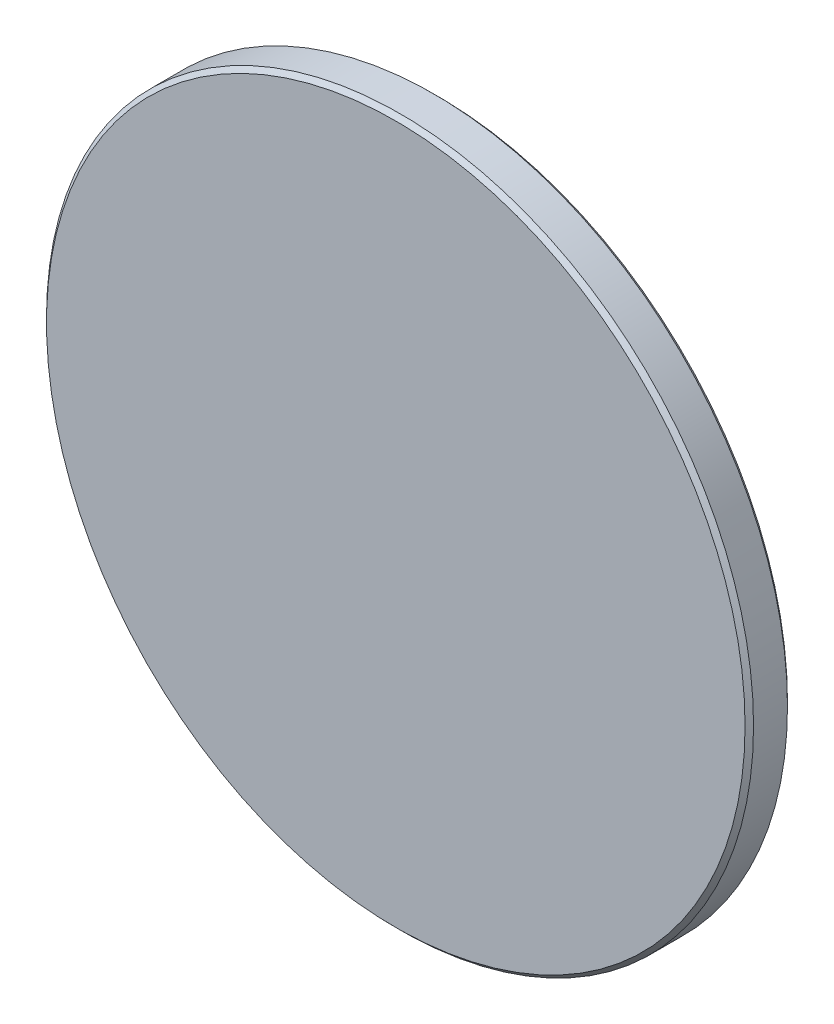
from build123d import *

# Parameters (mm, degrees)
SKETCH_1_R      = 25
EXTRUDE_1_DEPTH = 3
CHAMFER_1_SIZE  = 0.3


with BuildPart() as part:
    # 草图1 → 凸台-拉伸1 (new body)
    with BuildSketch(Plane.XY):
        Circle(SKETCH_1_R)
    extrude(amount=EXTRUDE_1_DEPTH)

    # 倒角1
    chamfer_1_edges = [part.edges().sort_by_distance(p)[0] for p in [
        (-25, 0, 0),
        (-25, 0, 3),
    ]]
    chamfer(chamfer_1_edges, length=CHAMFER_1_SIZE)


solid = part.part
